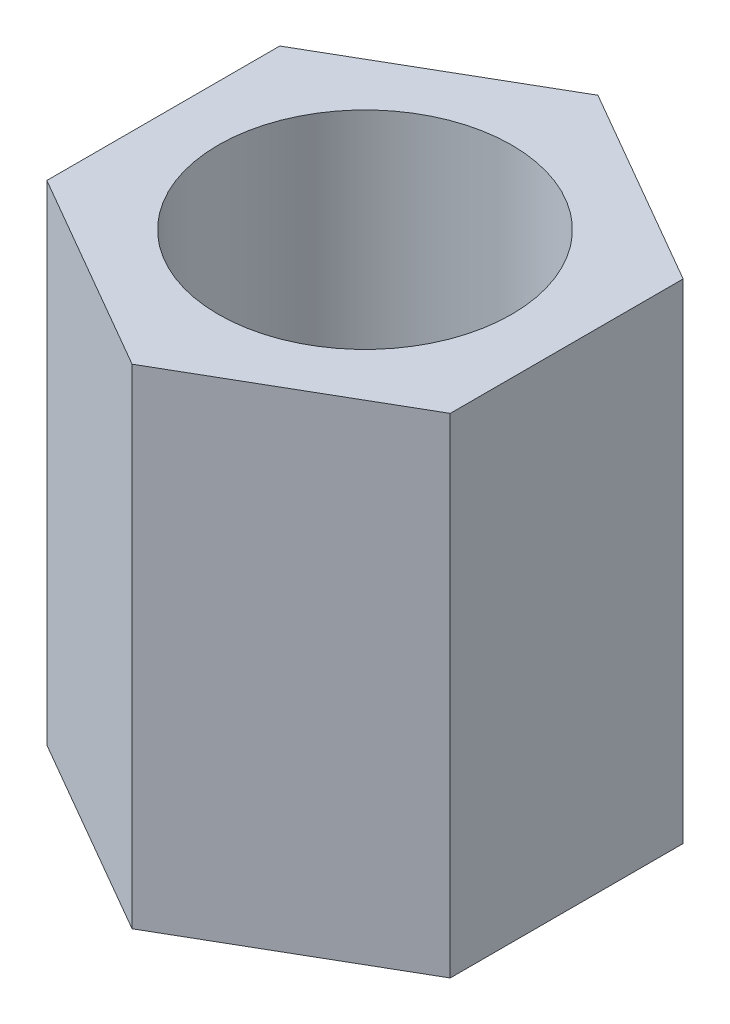
from build123d import *

# Parameters (mm, degrees)
SKETCH_1_R      = 3
EXTRUDE_1_DEPTH = 10


with BuildPart() as part:
    # 草图1 → 凸台-拉伸1 (new body)
    with BuildSketch(Plane(origin=(0, 0, 0), x_dir=(1, 0, 0), z_dir=(0, 1, 0))):
        Polygon((0, 4.763139721), (-4.125, 2.38156986), (-4.125, -2.38156986), (0, -4.763139721), (4.125, -2.38156986), (4.125, 2.38156986), align=None)
        Circle(SKETCH_1_R, mode=Mode.SUBTRACT)
    extrude(amount=EXTRUDE_1_DEPTH)


solid = part.part
